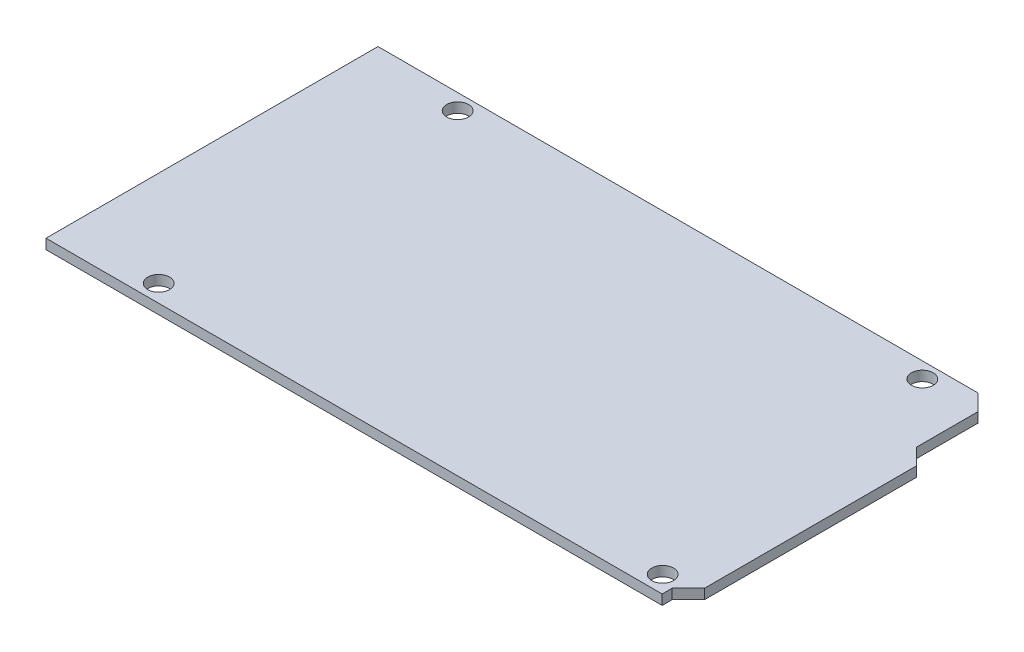
from build123d import *

# Parameters (mm, degrees)
BOSS_EXTRUDE1_DEPTH            = 1.6
F_3_5_3_5_DIAMETER_HOLE1_D     = 3.5
F_3_5_3_5_DIAMETER_HOLE1_DEPTH = 3
F_3_5_3_5_DIAMETER_HOLE1_TIP   = 1.051506083


with BuildPart() as part:
    # Sketch2 → Boss-Extrude1 (new body)
    with BuildSketch(Plane(origin=(0, 0, 0), x_dir=(1, 0, 0), z_dir=(0, 1, 0))):
        Polygon((50.8, -22.47), (50.8, 11.586871141), (48.2, 14.186871141), (48.2, 24.07), (45.6, 26.67), (-50.8, 26.67), (-50.8, -26.67), (48.2, -26.67), (48.2, -25.07), align=None)
    extrude(amount=BOSS_EXTRUDE1_DEPTH)

    # Ø3.5 (3.5) Diameter Hole1
    with Locations(Plane(origin=(0, 1.6, 0), x_dir=(-1, 0, 0), z_dir=(0, 1, 0))):
        with Locations((35.468438844, -24.132254762), (35.468438844, 23.898881858), (-45.502928223, 23.898881858), (-39.195511542, -24.132254762)):
            Hole(F_3_5_3_5_DIAMETER_HOLE1_D / 2, depth=F_3_5_3_5_DIAMETER_HOLE1_DEPTH)
            with Locations((0, 0, -(F_3_5_3_5_DIAMETER_HOLE1_DEPTH + F_3_5_3_5_DIAMETER_HOLE1_TIP / 2))):  # 118° drill point
                Cone(0, F_3_5_3_5_DIAMETER_HOLE1_D / 2, F_3_5_3_5_DIAMETER_HOLE1_TIP, mode=Mode.SUBTRACT)


solid = part.part
